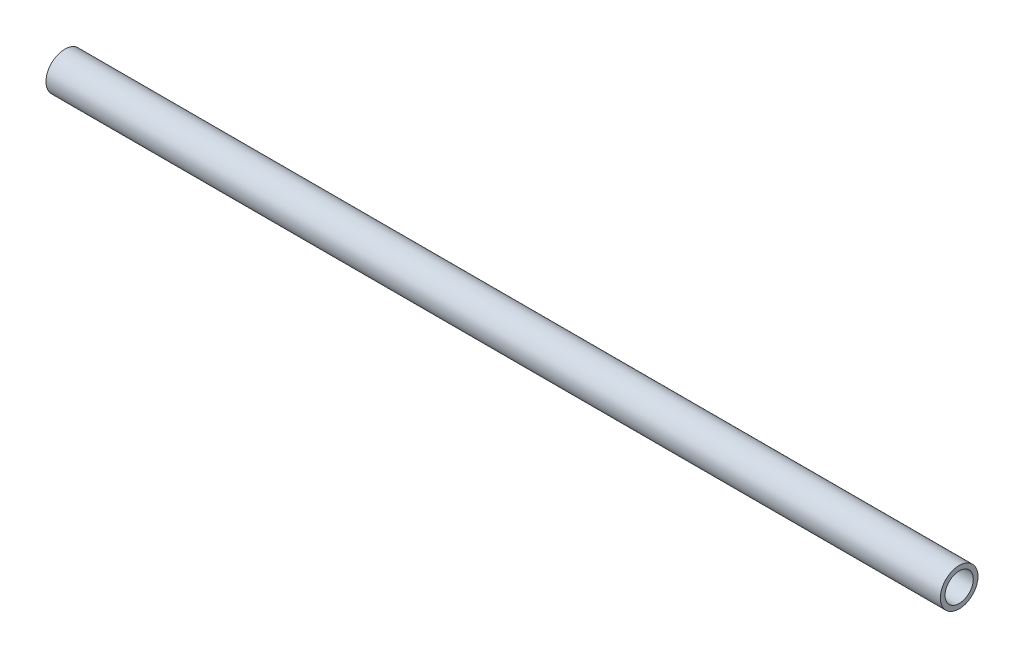
from build123d import *

# Parameters (mm, degrees)
SKETCH1_R           = 4
SKETCH1_R_2         = 3
BOSS_EXTRUDE1_DEPTH = 95


with BuildPart() as part:
    # Sketch1 → Boss-Extrude1 (new body, symmetric)
    with BuildSketch(Plane(origin=(0, 0, 0), x_dir=(0, 0, -1), z_dir=(1, 0, 0))):
        Circle(SKETCH1_R)
        Circle(SKETCH1_R_2, mode=Mode.SUBTRACT)
    extrude(amount=BOSS_EXTRUDE1_DEPTH, both=True)


solid = part.part
